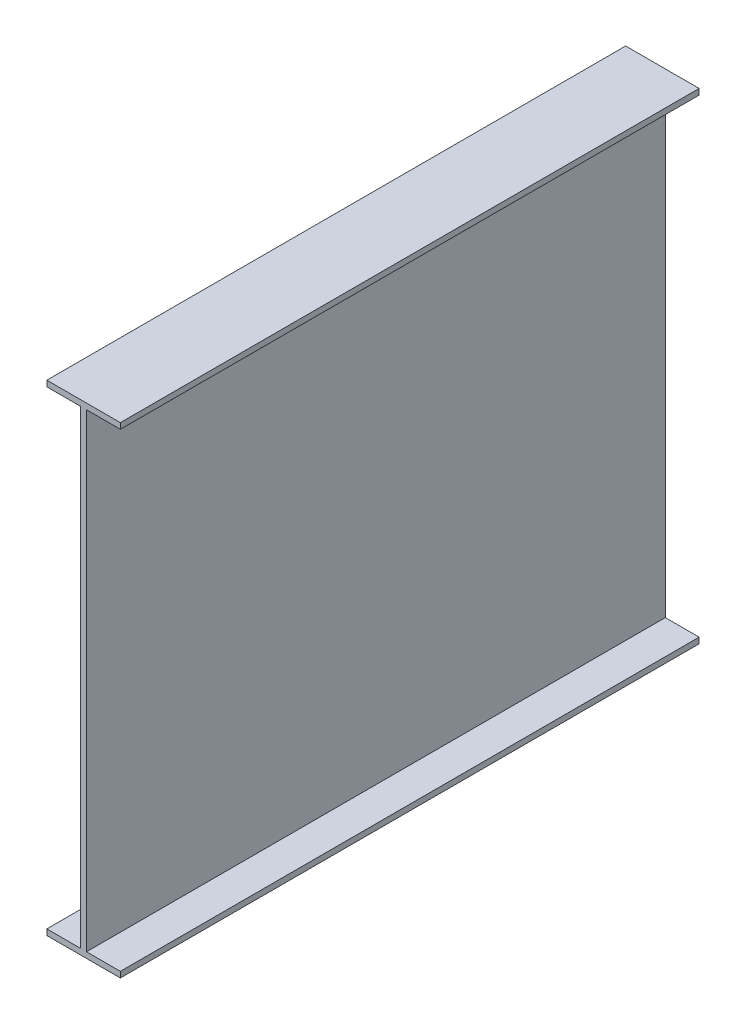
from build123d import *

# Parameters (mm, degrees)
BOSS_EXTRUDE1_DEPTH = 1000


with BuildPart() as part:
    # Sketch1 → Boss-Extrude1 (new body)
    with BuildSketch(Plane.XY):
        Polygon((0, 0), (0, 811), (-58.5, 811), (-58.5, 821), (68.5, 821), (68.5, 811), (10, 811), (10, 0), (68.5, 0), (68.5, -10), (-58.5, -10), (-58.5, 0), align=None)
    extrude(amount=-BOSS_EXTRUDE1_DEPTH)


solid = part.part
